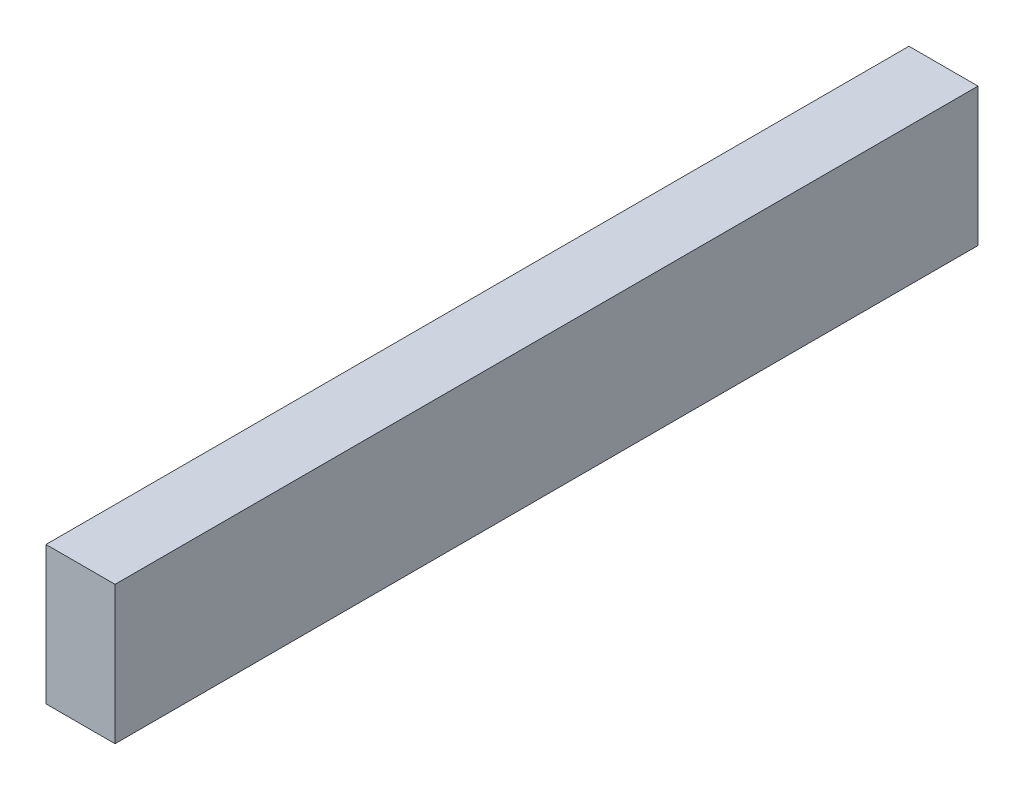
from build123d import *

# Parameters (mm, degrees)
BOSS_EXTRUDE1_DEPTH = 69
SKETCH4_W           = 15
SKETCH4_H           = 150.1
BOSS_EXTRUDE2_DEPTH = 61.9
BOSS_EXTRUDE3_DEPTH = 20.4
FILLET1_R           = 10
SKETCH6_W           = 1900
SKETCH6_H           = 304
BOSS_EXTRUDE4_DEPTH = 152


with BuildPart() as part:
    # Sketch2 → Boss-Extrude1 (new body, symmetric)
    with BuildSketch(Plane(origin=(0, 0, 0), x_dir=(0, 0, -1), z_dir=(1, 0, 0))):
        with BuildLine():
            Line((-262.793626597, 0), (0, 0))
            Line((0, 0), (165.1, 0))
            Line((165.1, 0), (165.1, 81.9))
            Line((165.1, 81.9), (150.1, 81.9))
            Line((150.1, 81.9), (150.1, 20))
            Line((150.1, 20), (0, 20))
            Line((0, 20), (0, 133.7))
            Line((0, 133.7), (-115, 133.7))
            Line((-115, 133.7), (-171.193830238, 94.352656466))
            Line((-171.193830238, 94.352656466), (-262.793626597, 81.479144628))
            Line((-262.793626597, 81.479144628), (-262.793626597, 31.479144628))
            ThreePointArc((-262.793626597, 31.479144628), (-272.644060375, 15.739572314), (-262.793626597, 0))
        make_face()
    extrude(amount=BOSS_EXTRUDE1_DEPTH, both=True)

    # Sketch4 → Boss-Extrude2 (add)
    with BuildSketch(Plane(origin=(0, 20, 0), x_dir=(1, 0, 0), z_dir=(0, 1, 0))):
        with Locations((61.5, 75.05)):
            Rectangle(SKETCH4_W, SKETCH4_H)
    boss_extrude2 = extrude(amount=BOSS_EXTRUDE2_DEPTH)

    # Mirror1: Boss-Extrude2 across plane
    add(boss_extrude2.mirror(Plane(origin=(0, 0, 0), x_dir=(0, 0, 1), z_dir=(1, 0, 0))))

    # Sketch5 → Boss-Extrude3 (add)
    with BuildSketch(Plane(origin=(69, 0, 0), x_dir=(0, 0, -1), z_dir=(1, 0, 0))):
        with BuildLine():
            Line((-224.944060375, 0), (-160.344060375, 0))
            ThreePointArc((-160.344060375, 0), (-192.644060375, -32.3), (-224.944060375, 0))
        make_face()
        with BuildLine():
            Line((28.055939625, 0), (92.655939625, 0))
            ThreePointArc((92.655939625, 0), (60.355939625, -32.3), (28.055939625, 0))
        make_face()
    boss_extrude3 = extrude(amount=-BOSS_EXTRUDE3_DEPTH)

    # Mirror2: Boss-Extrude3 across plane
    add(boss_extrude3.mirror(Plane(origin=(0, 0, 0), x_dir=(0, 0, 1), z_dir=(1, 0, 0))))

    # Fillet1
    fillet1_edges = [part.edges().sort_by_distance(p)[0] for p in [
        (0, 31.479144628, 262.793626597),
        (0, 81.479144628, 262.793626597),
        (0, 94.352656466, 171.193830238),
        (0, 133.7, 115),
        (0, 133.7, 0),
    ]]
    fillet(fillet1_edges, radius=FILLET1_R)


with BuildPart() as body_2:
    # Sketch6 → Boss-Extrude4 (new body)
    with BuildSketch(Plane(origin=(0, 0, 0), x_dir=(0, 0, -1), z_dir=(1, 0, 0))):
        with Locations((257.355939625, 119.7)):
            Rectangle(SKETCH6_W, SKETCH6_H)
    extrude(amount=BOSS_EXTRUDE4_DEPTH)


solid = Compound([part.part, body_2.part])
